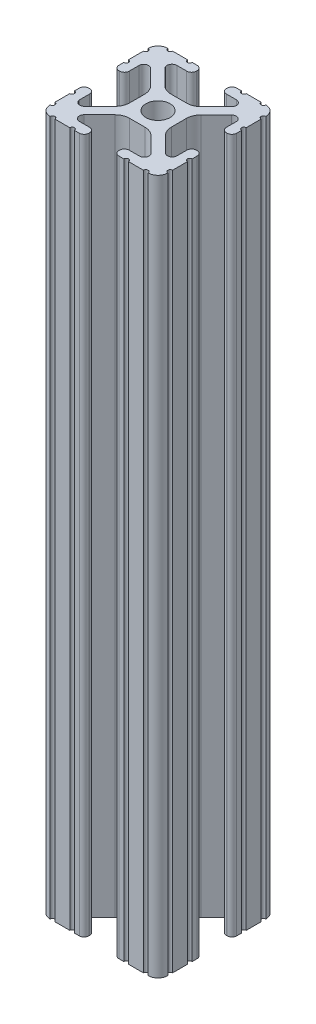
from build123d import *

# Parameters (mm, degrees)
SKETCH11_R                     = 2.6035
EXTRUSION_1010_PROFILE_1_DEPTH = 150
SKETCH12_R                     = 2.975
WRENCH_HOLE_DEPTH              = 153.66450144
SKETCH13_R                     = 2.975
WRENCH_HOLE_2_DEPTH            = 153.664501539


with BuildPart() as part:
    # Sketch11 → Extrusion 1010 PROFILE(1) (new body)
    with BuildSketch(Plane(origin=(0, 0, 0), x_dir=(-1, 0, 0), z_dir=(0, 1, 0))):
        with BuildLine():
            Line((-1.709253557, -4.4958), (1.709253557, -4.4958))
            ThreePointArc((1.709253557, -4.4958), (2.922935876, -4.736928798), (3.95226937, -5.423689619))
            Line((3.95226937, -5.423689619), (7.179652728, -8.645192207))
            ThreePointArc((7.179652728, -8.645192207), (7.414733441, -9.822812921), (6.41641086, -10.4902))
            Line((6.41641086, -10.4902), (4.28752, -10.4902))
            ThreePointArc((4.28752, -10.4902), (3.545750844, -10.797450844), (3.2385, -11.53922))
            Line((3.2385, -11.53922), (3.2385, -11.65098))
            ThreePointArc((3.2385, -11.65098), (3.545750844, -12.392749156), (4.28752, -12.7))
            Line((4.28752, -12.7), (5.3171344, -12.7))
            ThreePointArc((5.3171344, -12.7), (5.8251344, -12.192), (6.3331344, -12.7))
            Line((6.3331344, -12.7), (9.5504, -12.7))
            ThreePointArc((9.5504, -12.7), (10.058323491, -12.192000006), (10.566399977, -12.699846982))
            ThreePointArc((10.566399977, -12.699846982), (12.082522516, -12.082522516), (12.699846982, -10.566399977))
            ThreePointArc((12.699846982, -10.566399977), (12.192000006, -10.058323491), (12.7, -9.5504))
            Line((12.7, -9.5504), (12.7, -6.3330836))
            ThreePointArc((12.7, -6.3330836), (12.192, -5.8250836), (12.7, -5.3170836))
            Line((12.7, -5.3170836), (12.7, -4.287470133))
            ThreePointArc((12.7, -4.287470133), (12.392749156, -3.545700977), (11.65098, -3.238450133))
            Line((11.65098, -3.238450133), (11.53922, -3.238450133))
            ThreePointArc((11.53922, -3.238450133), (10.797450844, -3.545700977), (10.4902, -4.287470133))
            Line((10.4902, -4.287470133), (10.4902, -6.402089023))
            ThreePointArc((10.4902, -6.402089023), (9.856394933, -7.351113629), (8.736962546, -7.129240479))
            Line((8.736962546, -7.129240479), (5.440484187, -3.838768792))
            ThreePointArc((5.440484187, -3.838768792), (4.75073678, -2.808015636), (4.5085, -1.591658411))
            Line((4.5085, -1.591658411), (4.5085, 1.591658411))
            ThreePointArc((4.5085, 1.591658411), (4.75073678, 2.808015636), (5.440484187, 3.838768792))
            Line((5.440484187, 3.838768792), (8.736962546, 7.129240479))
            ThreePointArc((8.736962546, 7.129240479), (9.856394933, 7.351113629), (10.4902, 6.402089023))
            Line((10.4902, 6.402089023), (10.4902, 4.287470133))
            ThreePointArc((10.4902, 4.287470133), (10.797450844, 3.545700977), (11.53922, 3.238450133))
            Line((11.53922, 3.238450133), (11.65098, 3.238450133))
            ThreePointArc((11.65098, 3.238450133), (12.392749156, 3.545700977), (12.7, 4.287470133))
            Line((12.7, 4.287470133), (12.7, 5.3171344))
            ThreePointArc((12.7, 5.3171344), (12.192, 5.8251344), (12.7, 6.3331344))
            Line((12.7, 6.3331344), (12.7, 9.5504))
            ThreePointArc((12.7, 9.5504), (12.192000006, 10.058323491), (12.699846982, 10.566399977))
            ThreePointArc((12.699846982, 10.566399977), (12.082522516, 12.082522516), (10.566399977, 12.699846982))
            ThreePointArc((10.566399977, 12.699846982), (10.058323491, 12.192000006), (9.5504, 12.7))
            Line((9.5504, 12.7), (6.3330836, 12.7))
            ThreePointArc((6.3330836, 12.7), (5.8250836, 12.192), (5.3170836, 12.7))
            Line((5.3170836, 12.7), (4.2874692, 12.7))
            ThreePointArc((4.2874692, 12.7), (3.545700044, 12.392749156), (3.2384492, 11.65098))
            Line((3.2384492, 11.65098), (3.2384492, 11.53922))
            ThreePointArc((3.2384492, 11.53922), (3.545700044, 10.797450844), (4.2874692, 10.4902))
            Line((4.2874692, 10.4902), (6.476774195, 10.4902))
            ThreePointArc((6.476774195, 10.4902), (7.43216212, 9.851515102), (7.207191475, 8.724540082))
            Line((7.207191475, 8.724540082), (3.900315394, 5.423689619))
            ThreePointArc((3.900315394, 5.423689619), (2.8709819, 4.736928798), (1.657299581, 4.4958))
            Line((1.657299581, 4.4958), (-1.657299581, 4.4958))
            ThreePointArc((-1.657299581, 4.4958), (-2.8709819, 4.736928798), (-3.900315394, 5.423689619))
            Line((-3.900315394, 5.423689619), (-7.207191475, 8.724540082))
            ThreePointArc((-7.207191475, 8.724540082), (-7.43216212, 9.851515102), (-6.476774195, 10.4902))
            Line((-6.476774195, 10.4902), (-4.2874692, 10.4902))
            ThreePointArc((-4.2874692, 10.4902), (-3.545700044, 10.797450844), (-3.2384492, 11.53922))
            Line((-3.2384492, 11.53922), (-3.2384492, 11.65098))
            ThreePointArc((-3.2384492, 11.65098), (-3.545700044, 12.392749156), (-4.2874692, 12.7))
            Line((-4.2874692, 12.7), (-5.3170836, 12.7))
            ThreePointArc((-5.3170836, 12.7), (-5.8250836, 12.192), (-6.3330836, 12.7))
            Line((-6.3330836, 12.7), (-9.5504, 12.7))
            ThreePointArc((-9.5504, 12.7), (-10.058323491, 12.192000006), (-10.566399977, 12.699846982))
            ThreePointArc((-10.566399977, 12.699846982), (-12.082522516, 12.082522516), (-12.699846982, 10.566399977))
            ThreePointArc((-12.699846982, 10.566399977), (-12.192000006, 10.058323491), (-12.7, 9.5504))
            Line((-12.7, 9.5504), (-12.7, 6.3331344))
            ThreePointArc((-12.7, 6.3331344), (-12.192, 5.8251344), (-12.7, 5.3171344))
            Line((-12.7, 5.3171344), (-12.7, 4.287470133))
            ThreePointArc((-12.7, 4.287470133), (-12.392749156, 3.545700977), (-11.65098, 3.238450133))
            Line((-11.65098, 3.238450133), (-11.53922, 3.238450133))
            ThreePointArc((-11.53922, 3.238450133), (-10.797450844, 3.545700977), (-10.4902, 4.287470133))
            Line((-10.4902, 4.287470133), (-10.4902, 6.402089023))
            ThreePointArc((-10.4902, 6.402089023), (-9.856394933, 7.351113629), (-8.736962546, 7.129240479))
            Line((-8.736962546, 7.129240479), (-5.440484187, 3.838768792))
            ThreePointArc((-5.440484187, 3.838768792), (-4.75073678, 2.808015636), (-4.5085, 1.591658411))
            Line((-4.5085, 1.591658411), (-4.5085, -1.591658411))
            ThreePointArc((-4.5085, -1.591658411), (-4.75073678, -2.808015636), (-5.440484187, -3.838768792))
            Line((-5.440484187, -3.838768792), (-8.736962546, -7.129240479))
            ThreePointArc((-8.736962546, -7.129240479), (-9.856394933, -7.351113629), (-10.4902, -6.402089023))
            Line((-10.4902, -6.402089023), (-10.4902, -4.287470133))
            ThreePointArc((-10.4902, -4.287470133), (-10.797450844, -3.545700977), (-11.53922, -3.238450133))
            Line((-11.53922, -3.238450133), (-11.65098, -3.238450133))
            ThreePointArc((-11.65098, -3.238450133), (-12.392749156, -3.545700977), (-12.7, -4.287470133))
            Line((-12.7, -4.287470133), (-12.7, -5.3170836))
            ThreePointArc((-12.7, -5.3170836), (-12.192, -5.8250836), (-12.7, -6.3330836))
            Line((-12.7, -6.3330836), (-12.7, -9.5504))
            ThreePointArc((-12.7, -9.5504), (-12.192000006, -10.058323491), (-12.699846982, -10.566399977))
            ThreePointArc((-12.699846982, -10.566399977), (-12.082522516, -12.082522516), (-10.566399977, -12.699846982))
            ThreePointArc((-10.566399977, -12.699846982), (-10.058323491, -12.192000006), (-9.5504, -12.7))
            Line((-9.5504, -12.7), (-6.3331344, -12.7))
            ThreePointArc((-6.3331344, -12.7), (-5.8251344, -12.192), (-5.3171344, -12.7))
            Line((-5.3171344, -12.7), (-4.28752, -12.7))
            ThreePointArc((-4.28752, -12.7), (-3.545750844, -12.392749156), (-3.2385, -11.65098))
            Line((-3.2385, -11.65098), (-3.2385, -11.53922))
            ThreePointArc((-3.2385, -11.53922), (-3.545750844, -10.797450844), (-4.28752, -10.4902))
            Line((-4.28752, -10.4902), (-6.41641086, -10.4902))
            ThreePointArc((-6.41641086, -10.4902), (-7.414733441, -9.822812921), (-7.179652728, -8.645192207))
            Line((-7.179652728, -8.645192207), (-3.95226937, -5.423689619))
            ThreePointArc((-3.95226937, -5.423689619), (-2.922935876, -4.736928798), (-1.709253557, -4.4958))
        make_face()
        Circle(SKETCH11_R, mode=Mode.SUBTRACT)
    extrude(amount=EXTRUSION_1010_PROFILE_1_DEPTH)

    # Sketch12 → Wrench Hole (cut, through all)
    with BuildSketch(Plane.XY.offset(12.7)):
        with Locations(Location((0, 137.3, 0), (0, 0, 54.932644771))):
            Circle(SKETCH12_R)
        with Locations(Location((0, 12.7, 0), (0, 0, 54.932644771))):
            Circle(SKETCH12_R)
    extrude(amount=-WRENCH_HOLE_DEPTH, mode=Mode.SUBTRACT)

    # Sketch13 → Wrench Hole 2 (cut, through all)
    with BuildSketch(Plane.ZY.offset(12.7)):
        with Locations(Location((0, 137.3, 0), (0, 0, 308.229120645))):
            Circle(SKETCH13_R)
        with Locations(Location((0, 12.7, 0), (0, 0, 51.770879355))):
            Circle(SKETCH13_R)
    extrude(amount=-WRENCH_HOLE_2_DEPTH, mode=Mode.SUBTRACT)


solid = part.part
